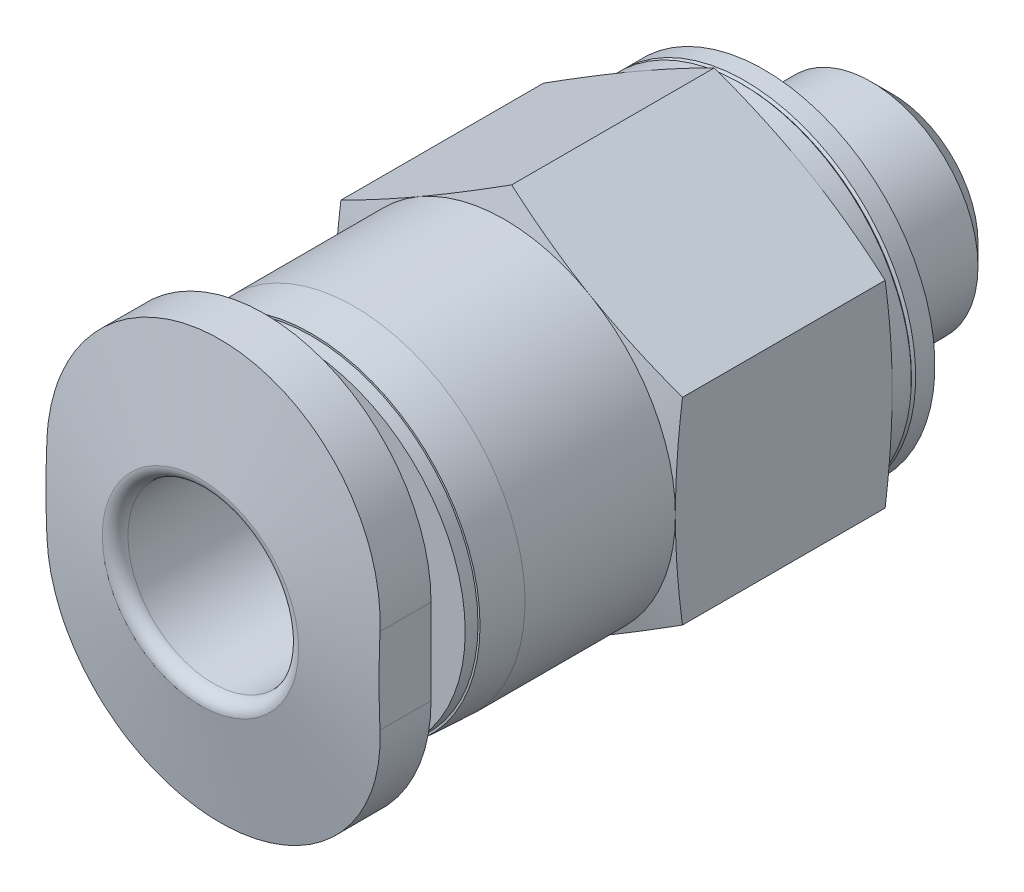
from build123d import *

# Parameters (mm, degrees)
CUT_EXTRUDE1_DEPTH = 1.5
SKETCH3_W          = 16
SKETCH3_H          = 16
CUT_EXTRUDE2_DEPTH = 7.7


with BuildPart() as part:
    # Sketch1 → Revolve1 (revolve)
    with BuildSketch(Plane(origin=(0, 0, 0), x_dir=(0, 0, -1), z_dir=(1, 0, 0))):
        with BuildLine():
            Line((-13.2, 0), (-13.2, 2.3))
            Line((-13.2, 2.3), (-12.735426078, 4.934729636))
            ThreePointArc((-12.735426078, 4.934729636), (-12.66702205, 5.053208889), (-12.538464528, 5.1))
            Line((-12.538464528, 5.1), (-11.7, 5.1))
            Line((-11.7, 5.1), (-11.7, 3.075))
            ThreePointArc((-11.7, 3.075), (-11.590165043, 2.809834957), (-11.325, 2.7))
            Line((-11.325, 2.7), (-10.9, 2.7))
            Line((-10.9, 2.7), (-10.9, 3.9))
            Line((-10.9, 3.9), (-10.6, 3.9))
            Line((-10.6, 3.9), (-10.6, 3.947592221))
            Line((-10.6, 3.947592221), (-9.6, 4))
            Line((-9.6, 4), (-6.076923077, 4))
            Line((-6.076923077, 4), (-5.905435594, 4.64))
            Line((-5.905435594, 4.64), (-1.171487483, 4.64))
            Line((-1.171487483, 4.64), (-1, 4))
            Line((-1, 4), (-0.55, 4))
            Line((-0.55, 4), (-0.5, 3.95))
            Line((-0.5, 3.95), (-0.45, 4))
            Line((-0.45, 4), (0, 4))
            Line((0, 4), (0, 0))
            Line((0, 0), (-13.2, 0))
        make_face()
    revolve(axis=Axis((0, 0, 0), (0, 0, 1)))

    # Sketch2 → Cut-Extrude1 (cut)
    with BuildSketch(Plane.XY.offset(13.2)):
        Polygon((-5.88, -3.394819583), (0, -6.789639166), (5.88, -3.394819583), (5.88, 3.394819583), (0, 6.789639166), (-5.88, 3.394819583), align=None)
        with BuildLine():
            Line((-3.9, 1), (-3.9, -1))
            ThreePointArc((-3.9, -1), (-2.757716447, -3.757716447), (0, -4.9))
            ThreePointArc((0, -4.9), (2.757716447, -3.757716447), (3.9, -1))
            Line((3.9, -1), (3.9, 1))
            ThreePointArc((3.9, 1), (2.757716447, 3.757716447), (0, 4.9))
            ThreePointArc((0, 4.9), (-2.757716447, 3.757716447), (-3.9, 1))
        make_face(mode=Mode.SUBTRACT)
    extrude(amount=-CUT_EXTRUDE1_DEPTH, mode=Mode.SUBTRACT)

    # Sketch3 → Cut-Extrude2 (cut)
    with BuildSketch(Plane.XY):
        Rectangle(SKETCH3_W, SKETCH3_H)
        Polygon((-4, -2.309401077), (0, -4.618802154), (4, -2.309401077), (4, 2.309401077), (0, 4.618802154), (-4, 2.309401077), align=None, mode=Mode.SUBTRACT)
    extrude(amount=CUT_EXTRUDE2_DEPTH, mode=Mode.SUBTRACT)

    # Sketch4 → Revolve2 (revolve)
    with BuildSketch(Plane(origin=(0, 0, 0), x_dir=(0, 0, -1), z_dir=(1, 0, 0))):
        Polygon((0, 0), (0, 2.5), (2.5095, 2.5), (3, 2.0095), (3, 0), align=None)
    revolve(axis=Axis((0, 0, -3), (0, 0, 1)))

    # Sketch5 → Cut-Revolve1 (revolve, cut)
    with BuildSketch(Plane(origin=(0, 0, 0), x_dir=(0, 0, -1), z_dir=(1, 0, 0))):
        with BuildLine():
            Line((-13.2, 0), (-13.2, 2.3))
            ThreePointArc((-13.2, 2.3), (-13.112132034, 2.087867966), (-12.9, 2))
            Line((-12.9, 2), (-1.7, 2))
            Line((-1.7, 2), (-1.7, 1.1))
            Line((-1.7, 1.1), (3, 1.1))
            Line((3, 1.1), (3, 0))
            Line((3, 0), (-13.2, 0))
        make_face()
    revolve(axis=Axis((0, 0, -3), (0, 0, 1)), mode=Mode.SUBTRACT)


solid = part.part
